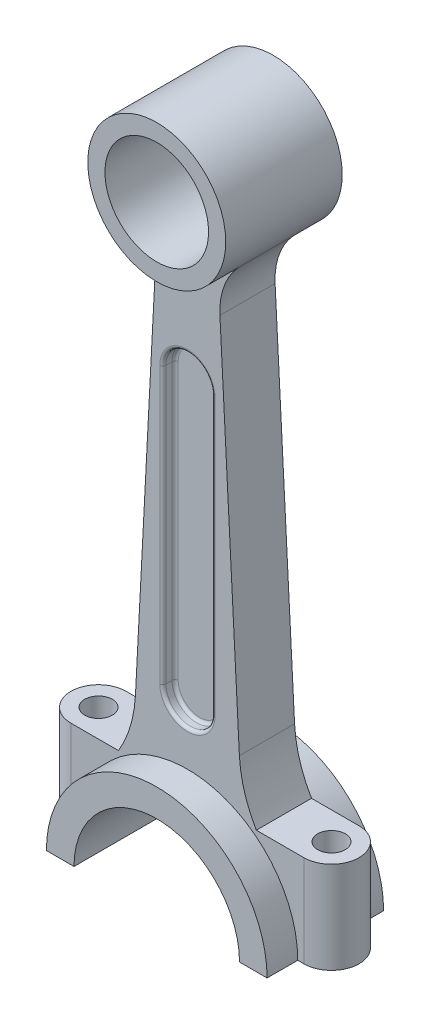
from build123d import *

# Parameters (mm, degrees)
SKETCH1_R             = 22.5
SKETCH1_R_2           = 16.9
BOSS_EXTRUDE1_DEPTH   = 19
BOSS_EXTRUDE1_2_DEPTH = 19
BOSS_EXTRUDE2_DEPTH   = 9
CUT_EXTRUDE1_DEPTH    = 4
FILLET1_R             = 1
FILLET2_R             = 40
FILLET3_R             = 22.5
BOSS_EXTRUDE5_DEPTH   = 30
SKETCH6_R             = 27
CUT_EXTRUDE2_DEPTH    = 37
SKETCH7_R             = 4.5
CUT_EXTRUDE3_DEPTH    = 37


with BuildPart() as part:
    # Sketch1 → Boss-Extrude1 (new body, symmetric)
    with BuildSketch(Plane.XY):
        Circle(SKETCH1_R)
        Circle(SKETCH1_R_2, mode=Mode.SUBTRACT)
    extrude(amount=BOSS_EXTRUDE1_DEPTH, both=True)



with BuildPart() as body_2:
    # Sketch1 → Boss-Extrude1 2 (new body, symmetric)
    with BuildSketch(Plane.XY):
        with BuildLine():
            Line((-36, -201.2), (-27, -201.2))
            ThreePointArc((-27, -201.2), (0, -174.2), (27, -201.2))
            Line((27, -201.2), (36, -201.2))
            ThreePointArc((36, -201.2), (0, -165.2), (-36, -201.2))
        make_face()
    extrude(amount=BOSS_EXTRUDE1_2_DEPTH, both=True)


with BuildPart() as part_1:
    add(part.part)

    add(body_2.part)  # Boss-Extrude2 merges body 2
    # Sketch1_3 → Boss-Extrude2 (add, symmetric)
    with BuildSketch(Plane.XY):
        with BuildLine():
            ThreePointArc((10, -20.155644371), (0, -22.5), (-10, -20.155644371))
            Line((-10, -20.155644371), (-17.849697213, -169.936789841))
            ThreePointArc((-17.849697213, -169.936789841), (0, -165.2), (17.849697213, -169.936789841))
            Line((17.849697213, -169.936789841), (10, -20.155644371))
        make_face()
    extrude(amount=BOSS_EXTRUDE2_DEPTH, both=True)

    # Sketch2 → Cut-Extrude1 (cut)
    with BuildSketch(Plane.XY.offset(9)):
        with BuildLine():
            Line((-8, -145.6), (-8, -55.6))
            ThreePointArc((-8, -55.6), (0, -47.6), (8, -55.6))
            Line((8, -55.6), (8, -145.6))
            ThreePointArc((8, -145.6), (0, -153.6), (-8, -145.6))
        make_face()
    cut_extrude1 = extrude(amount=-CUT_EXTRUDE1_DEPTH, mode=Mode.SUBTRACT)

    # Mirror1: Cut-Extrude1 across plane
    add(cut_extrude1.mirror(Plane.XY), mode=Mode.SUBTRACT)

    # Fillet1
    fillet1_edges = [part_1.edges().sort_by_distance(p)[0] for p in [
        (8, -100.6, 5),
        (0, -153.6, 5),
        (-8, -100.6, 9),
        (0, -47.6, 5),
        (-8, -100.6, 5),
        (8, -100.6, 9),
        (0, -47.6, 9),
        (0, -153.6, 9),
        (8, -100.6, -9),
        (0, -47.6, -9),
        (-8, -100.6, -5),
        (0, -153.6, -9),
        (8, -100.6, -5),
        (0, -47.6, -5),
        (0, -153.6, -5),
        (-8, -100.6, -9),
    ]]
    fillet(fillet1_edges, radius=FILLET1_R)

    # Fillet2
    fillet2_edges = [part_1.edges().sort_by_distance(p)[0] for p in [
        (-17.849697213, -169.936789841, 0),
        (17.849697213, -169.936789841, 0),
    ]]
    fillet(fillet2_edges, radius=FILLET2_R)

    # Fillet3
    fillet3_edges = [part_1.edges().sort_by_distance(p)[0] for p in [
        (10, -20.155644371, 0),
        (-10, -20.155644371, 0),
    ]]
    fillet(fillet3_edges, radius=FILLET3_R)

    # Sketch3 → Boss-Extrude5 (add)
    with BuildSketch(Plane(origin=(0, -171.2, 0), x_dir=(-1, 0, 0), z_dir=(0, -1, 0))):
        with BuildLine():
            Line((38, -9), (-38, -9))
            ThreePointArc((-38, -9), (-47, 0), (-38, 9))
            Line((-38, 9), (38, 9))
            ThreePointArc((38, 9), (47, 0), (38, -9))
        make_face()
    extrude(amount=BOSS_EXTRUDE5_DEPTH)

    # Sketch6 → Cut-Extrude2 (cut)
    with BuildSketch(Plane(origin=(0, 0, -9), x_dir=(-1, 0, 0), z_dir=(0, 0, -1))):
        with Locations((0, -201.2)):
            Circle(SKETCH6_R)
    extrude(amount=-CUT_EXTRUDE2_DEPTH, mode=Mode.SUBTRACT)

    # Sketch7 → Cut-Extrude3 (cut)
    with BuildSketch(Plane(origin=(0, -171.2, 0), x_dir=(-1, 0, 0), z_dir=(0, -1, 0))):
        with Locations((-38, 0)):
            Circle(SKETCH7_R)
        with Locations((38, 0)):
            Circle(SKETCH7_R)
    extrude(amount=CUT_EXTRUDE3_DEPTH, mode=Mode.SUBTRACT)


solid = part_1.part
